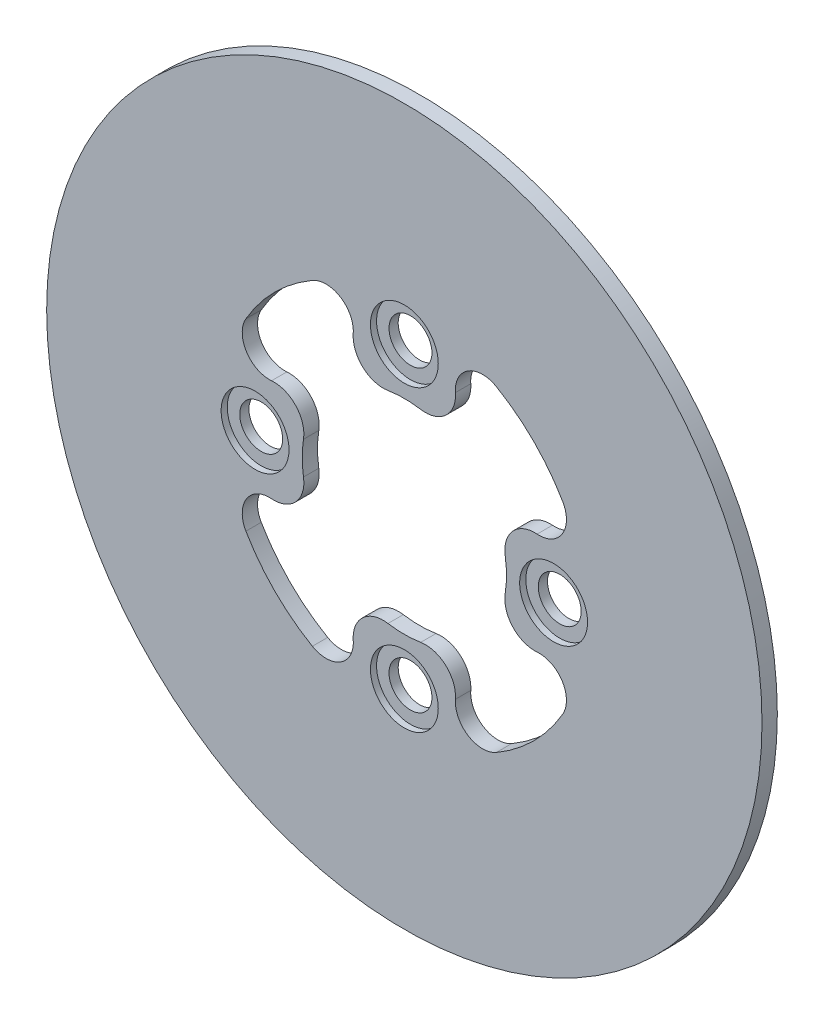
from build123d import *

# Parameters (mm, degrees)
CROQUIS1_R              = 87.5
SALIENTE_EXTRUIR1_DEPTH = 3.75
CROQUIS2_R              = 8.3
CORTAR_EXTRUIR1_DEPTH   = 1.5
CROQUIS3_R              = 5.25
CORTAR_EXTRUIR2_DEPTH   = 4.75
MATRIZC1_COUNT          = 8


with BuildPart() as part:
    # Croquis1 → Saliente-Extruir1 (new body)
    with BuildSketch(Plane.XY):
        Circle(CROQUIS1_R)
        with BuildLine():
            ThreePointArc((-38.757376395, -22.5), (-31.688990399, -31.688990399), (-22.5, -38.757376395))
            ThreePointArc((-22.5, -38.757376395), (-15.606593782, -38.639265866), (-12.5, -32.484424319))
            ThreePointArc((-12.5, -32.484424319), (-10.144121841, -26.518786087), (-4, -24.677925359))
            ThreePointArc((-4, -24.677925359), (0, -25), (4, -24.677925359))
            ThreePointArc((4, -24.677925359), (10.144121841, -26.518786087), (12.5, -32.484424319))
            ThreePointArc((12.5, -32.484424319), (15.606593782, -38.639265866), (22.5, -38.757376395))
            ThreePointArc((22.5, -38.757376395), (31.688990399, -31.688990399), (38.757376395, -22.5))
            ThreePointArc((38.757376395, -22.5), (38.639265866, -15.606593782), (32.484424319, -12.5))
            ThreePointArc((32.484424319, -12.5), (26.518786087, -10.144121841), (24.677925359, -4))
            ThreePointArc((24.677925359, -4), (25, 0), (24.677925359, 4))
            ThreePointArc((24.677925359, 4), (26.518786087, 10.144121841), (32.484424319, 12.5))
            ThreePointArc((32.484424319, 12.5), (38.639265866, 15.606593782), (38.757376395, 22.5))
            ThreePointArc((38.757376395, 22.5), (31.688990399, 31.688990399), (22.5, 38.757376395))
            ThreePointArc((22.5, 38.757376395), (15.606593782, 38.639265866), (12.5, 32.484424319))
            ThreePointArc((12.5, 32.484424319), (10.144121841, 26.518786087), (4, 24.677925359))
            ThreePointArc((4, 24.677925359), (0, 25), (-4, 24.677925359))
            ThreePointArc((-4, 24.677925359), (-10.144121841, 26.518786087), (-12.5, 32.484424319))
            ThreePointArc((-12.5, 32.484424319), (-15.606593782, 38.639265866), (-22.5, 38.757376395))
            ThreePointArc((-22.5, 38.757376395), (-31.688990399, 31.688990399), (-38.757376395, 22.5))
            ThreePointArc((-38.757376395, 22.5), (-38.639265866, 15.606593782), (-32.484424319, 12.5))
            ThreePointArc((-32.484424319, 12.5), (-26.518786087, 10.144121841), (-24.677925359, 4))
            ThreePointArc((-24.677925359, 4), (-25, 0), (-24.677925359, -4))
            ThreePointArc((-24.677925359, -4), (-26.518786087, -10.144121841), (-32.484424319, -12.5))
            ThreePointArc((-32.484424319, -12.5), (-38.639265866, -15.606593782), (-38.757376395, -22.5))
        make_face(mode=Mode.SUBTRACT)
    extrude(amount=SALIENTE_EXTRUIR1_DEPTH)

    # Croquis2 → Cortar-Extruir1 (cut)
    with BuildSketch(Plane.XY.offset(3.75)):
        with Locations((-36.515, 0)):
            Circle(CROQUIS2_R)
        with Locations((0, 36.515)):
            Circle(CROQUIS2_R)
        with Locations((36.515, 0)):
            Circle(CROQUIS2_R)
        with Locations((0, -36.515)):
            Circle(CROQUIS2_R)
    extrude(amount=-CORTAR_EXTRUIR1_DEPTH, mode=Mode.SUBTRACT)

    # Croquis3 → Cortar-Extruir2 (cut, through all)
    with BuildSketch(Plane.XY.offset(3.75)):
        with Locations((0, 36.515)):
            Circle(CROQUIS3_R)
    cortar_extruir2 = extrude(amount=-CORTAR_EXTRUIR2_DEPTH, mode=Mode.SUBTRACT)

    # MatrizC1: Cortar-Extruir2 ×8 about axis
    matrizc1_axis = Axis((0, 0, 3.75), (0, 0, 1))
    for i in range(1, MATRIZC1_COUNT):
        add(cortar_extruir2.rotate(matrizc1_axis, i * 360 / MATRIZC1_COUNT), mode=Mode.SUBTRACT)


solid = part.part
